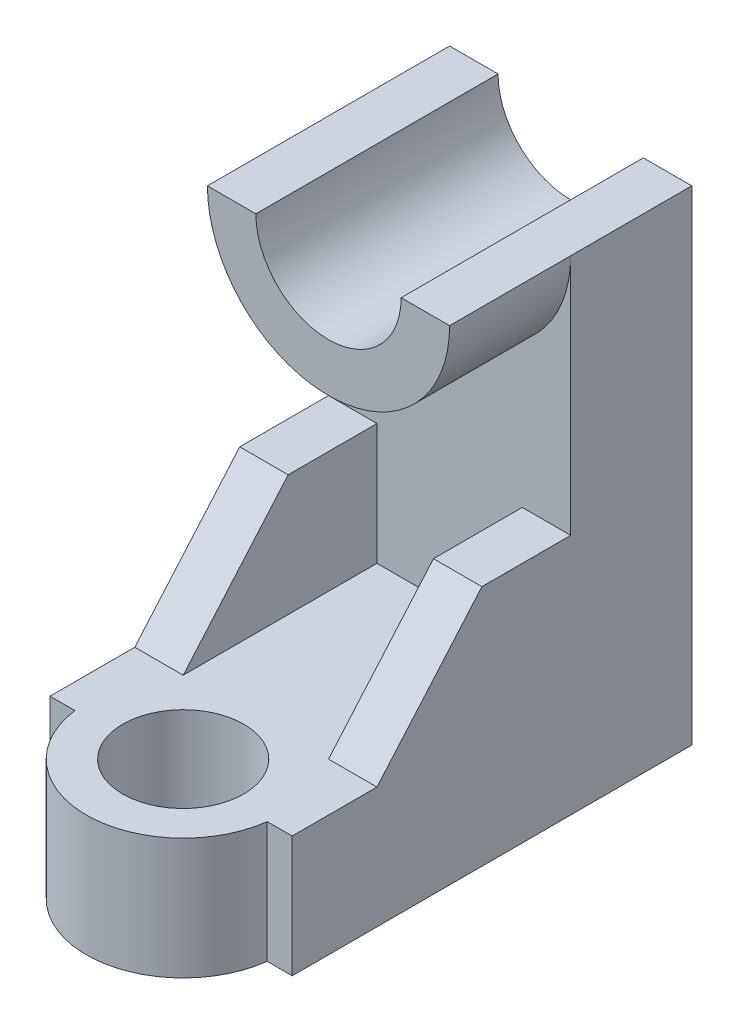
from build123d import *

# Parameters (mm, degrees)
BOSS_EXTRUDE2_DEPTH = 100
SKETCH1_4_W         = 10
SKETCH1_4_H         = 25
BOSS_EXTRUDE3_DEPTH = 65
BOSS_EXTRUDE4_DEPTH = 25
BOSS_EXTRUDE5_DEPTH = 50
SKETCH4_R           = 12.5
CUT_EXTRUDE1_DEPTH  = 56
CUT_EXTRUDE2_DEPTH  = 56


with BuildPart() as part:
    # Sketch1 → Boss-Extrude2 (new body)
    with BuildSketch(Plane.XY):
        Polygon((-85.137096774, -40.82358871), (-85.137096774, -65.82358871), (-35.137096774, -65.82358871), (-35.137096774, -40.82358871), (-45.137096774, -40.82358871), (-75.137096774, -40.82358871), align=None)
    extrude(amount=BOSS_EXTRUDE2_DEPTH)

    # Sketch1_4 → Boss-Extrude3 (add)
    with BuildSketch(Plane.XY):
        with Locations((-80.137096774, -28.32358871)):
            Rectangle(SKETCH1_4_W, SKETCH1_4_H)
        with Locations((-40.137096774, -28.32358871)):
            Rectangle(SKETCH1_4_W, SKETCH1_4_H)
    extrude(amount=BOSS_EXTRUDE3_DEPTH)

    # Sketch1_5 → Boss-Extrude4 (add)
    with BuildSketch(Plane.XY):
        with BuildLine():
            Line((-75.137096774, -15.82358871), (-75.137096774, -40.82358871))
            Line((-75.137096774, -40.82358871), (-45.137096774, -40.82358871))
            Line((-45.137096774, -40.82358871), (-45.137096774, -15.82358871))
            Line((-45.137096774, -15.82358871), (-35.137096774, -15.82358871))
            Line((-35.137096774, -15.82358871), (-35.137096774, 34.17641129))
            ThreePointArc((-35.137096774, 34.17641129), (-60.137096774, 9.17641129), (-85.137096774, 34.17641129))
            Line((-85.137096774, 34.17641129), (-85.137096774, -15.82358871))
            Line((-85.137096774, -15.82358871), (-75.137096774, -15.82358871))
        make_face()
    extrude(amount=BOSS_EXTRUDE4_DEPTH)

    # Sketch1_6 → Boss-Extrude5 (add)
    with BuildSketch(Plane.XY):
        with BuildLine():
            Line((-75.137096774, 34.17641129), (-85.137096774, 34.17641129))
            ThreePointArc((-85.137096774, 34.17641129), (-60.137096774, 9.17641129), (-35.137096774, 34.17641129))
            Line((-35.137096774, 34.17641129), (-45.137096774, 34.17641129))
            ThreePointArc((-45.137096774, 34.17641129), (-60.137096774, 19.17641129), (-75.137096774, 34.17641129))
        make_face()
    extrude(amount=BOSS_EXTRUDE5_DEPTH)

    # Sketch4 → Cut-Extrude1 (cut)
    with BuildSketch(Plane(origin=(0, -40.82358871, 0), x_dir=(1, 0, 0), z_dir=(0, 1, 0))):
        with BuildLine():
            Line((-35.137096774, -100), (-35.137096774, -82.5))
            Line((-35.137096774, -82.5), (-40.293961941, -82.5))
            ThreePointArc((-40.293961941, -82.5), (-46.908340219, -95), (-60.137096774, -100))
            Line((-60.137096774, -100), (-35.137096774, -100))
        make_face()
        with BuildLine():
            Line((-85.137096774, -100), (-60.137096774, -100))
            ThreePointArc((-60.137096774, -100), (-73.36585333, -95), (-79.980231607, -82.5))
            Line((-79.980231607, -82.5), (-85.137096774, -82.5))
            Line((-85.137096774, -82.5), (-85.137096774, -100))
        make_face()
        with Locations((-60.137096774, -80)):
            Circle(SKETCH4_R)
    extrude(amount=-CUT_EXTRUDE1_DEPTH, mode=Mode.SUBTRACT)

    # Sketch7 → Cut-Extrude2 (cut)
    with BuildSketch(Plane(origin=(-35.137096774, 0, 0), x_dir=(0, 0, -1), z_dir=(1, 0, 0))):
        Polygon((-65, -15.82358871), (-65, -40.82358871), (-43.333333333, -15.82358871), align=None)
    extrude(amount=-CUT_EXTRUDE2_DEPTH, mode=Mode.SUBTRACT)


solid = part.part
